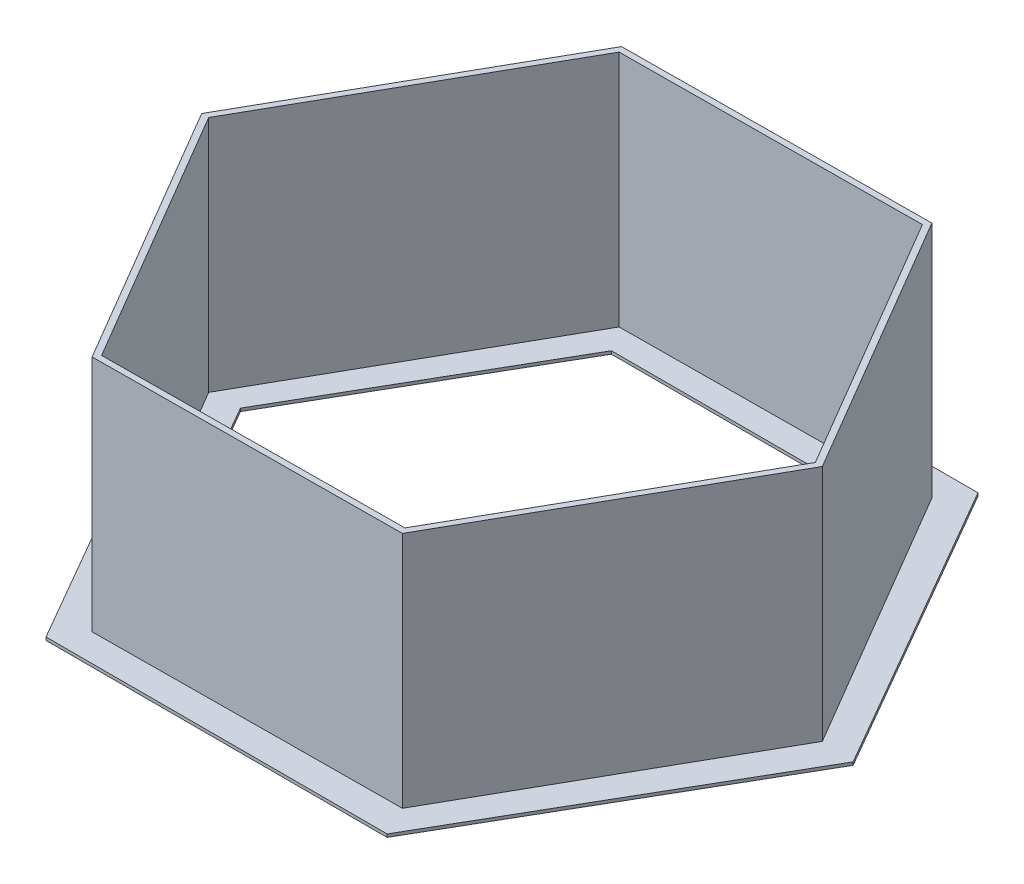
from build123d import *

# Parameters (mm, degrees)
BOSS_EXTRUDE1_DEPTH = 2.54
BOSS_EXTRUDE2_DEPTH = 203.2


with BuildPart() as part:
    # Sketch1 → Boss-Extrude1 (new body)
    with BuildSketch(Plane(origin=(0, 0, 0), x_dir=(1, 0, 0), z_dir=(0, 1, 0))):
        Polygon((143.769509274, -249.016094641), (287.539018547, 0), (143.769509274, 249.016094641), (-143.769509274, 249.016094641), (-287.539018547, 0), (-143.769509274, -249.016094641), align=None)
        Polygon((114.440115599, -198.216094641), (228.880231198, 0), (114.440115599, 198.216094641), (-114.440115599, 198.216094641), (-228.880231198, 0), (-114.440115599, -198.216094641), align=None, mode=Mode.SUBTRACT)
    extrude(amount=BOSS_EXTRUDE1_DEPTH)

    # Sketch2 → Boss-Extrude2 (add)
    with BuildSketch(Plane(origin=(0, 0, 0), x_dir=(1, 0, 0), z_dir=(0, 1, 0))):
        Polygon((128.11073119, 225.819195391), (-131.509794276, 223.856745403), (-259.620525466, -1.962449988), (-128.11073119, -225.819195391), (131.509794276, -223.856745403), (259.620525466, 1.962449988), align=None)
        Polygon((125.21627381, 220.717171301), (-128.538540494, 218.799059737), (-253.754814303, -1.918111564), (-125.21627381, -220.717171301), (128.538540494, -218.799059737), (253.754814303, 1.918111564), align=None, mode=Mode.SUBTRACT)
    extrude(amount=BOSS_EXTRUDE2_DEPTH)


solid = part.part
